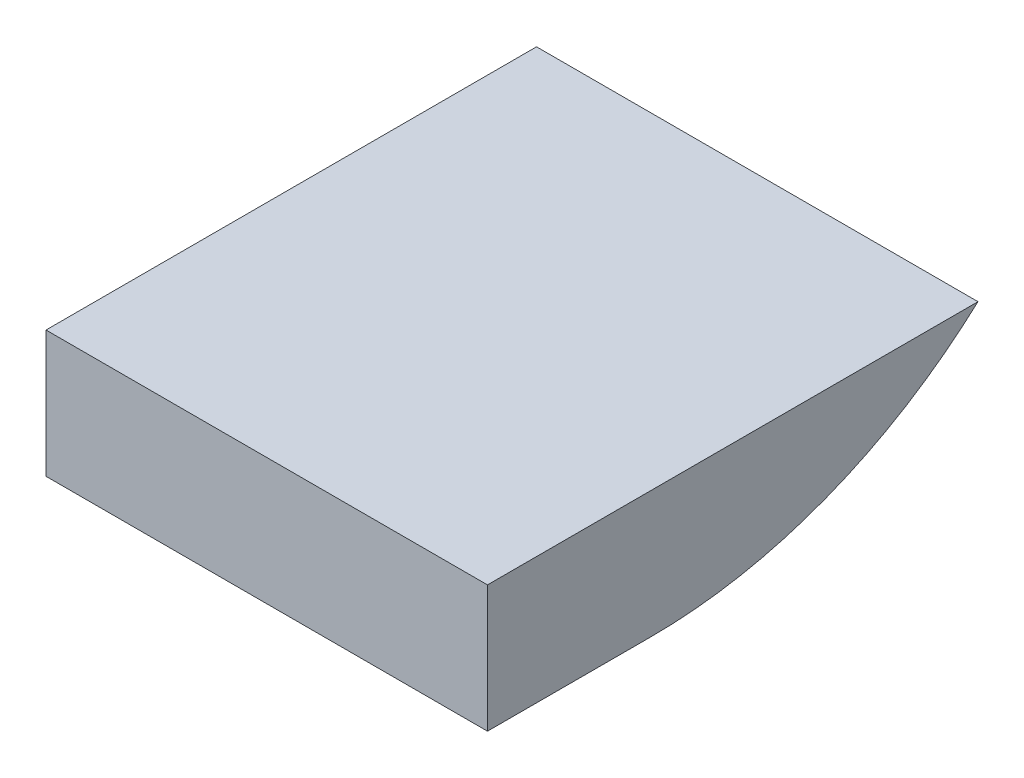
from build123d import *

# Parameters (mm, degrees)
BOSS_EXTRUDE1_DEPTH = 10.8


with BuildPart() as part:
    # Sketch3 → Boss-Extrude1 (new body)
    with BuildSketch(Plane(origin=(0, 0, 0), x_dir=(0, 0, -1), z_dir=(1, 0, 0))):
        with BuildLine():
            Line((-2, -1.55), (0, -1.55))
            Line((0, -1.55), (2, -1.55))
            ThreePointArc((2, -1.55), (6.289813516, -0.747905847), (10, 1.55))
            Line((10, 1.55), (-2, 1.55))
            Line((-2, 1.55), (-2, -1.55))
        make_face()
    extrude(amount=BOSS_EXTRUDE1_DEPTH)


solid = part.part
